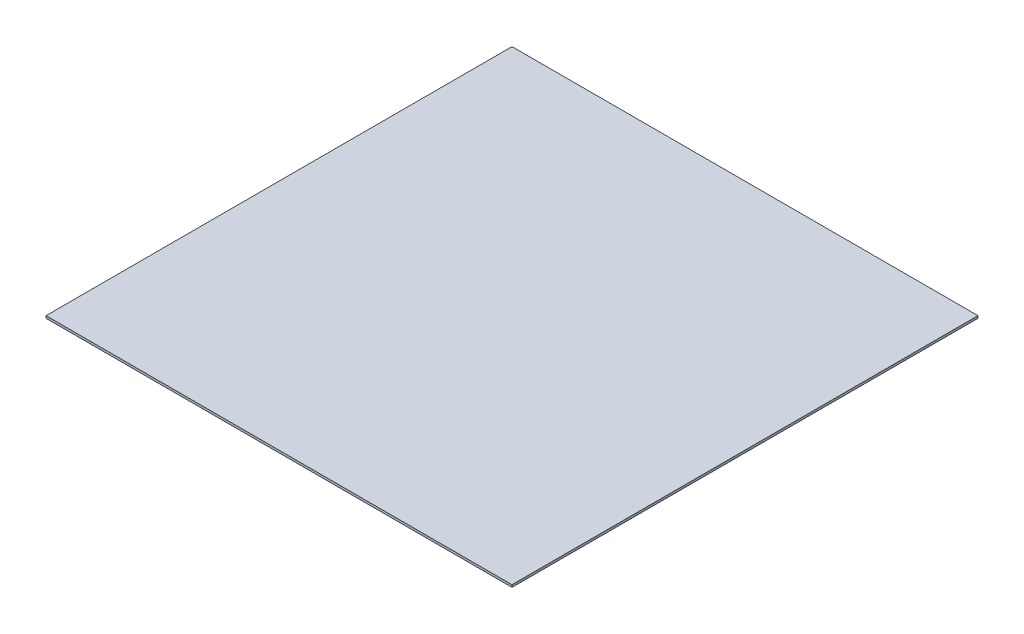
from build123d import *

# Parameters (mm, degrees)
SKETCH_1_W      = 2000
SKETCH_1_H      = 2000
EXTRUDE_1_DEPTH = 10


with BuildPart() as part:
    # Эскиз1 → Бобышка-Вытянуть1 (new body)
    with BuildSketch(Plane(origin=(0, 0, 0), x_dir=(1, 0, 0), z_dir=(0, 1, 0))):
        Rectangle(SKETCH_1_W, SKETCH_1_H)
    extrude(amount=EXTRUDE_1_DEPTH)


solid = part.part
